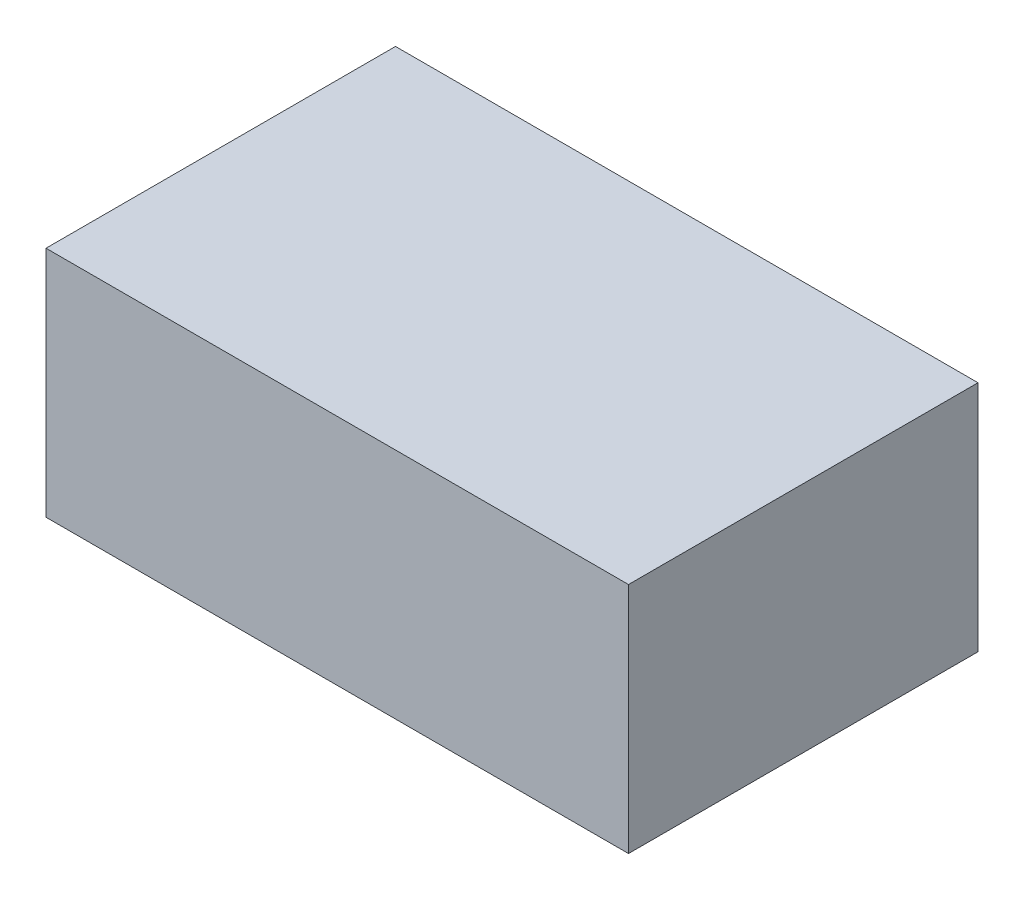
from build123d import *

# Parameters (mm, degrees)
SKETCH1_W           = 1
SKETCH1_H           = 0.6
BOSS_EXTRUDE1_DEPTH = 0.4
SKETCH2_W           = 0.25
SKETCH2_H           = 0.5
BOSS_EXTRUDE2_DEPTH = 0.05


with BuildPart() as part:
    # Sketch1 → Boss-Extrude1 (new body)
    with BuildSketch(Plane(origin=(0, 0, 0), x_dir=(1, 0, 0), z_dir=(0, 1, 0))):
        Rectangle(SKETCH1_W, SKETCH1_H)
    extrude(amount=BOSS_EXTRUDE1_DEPTH)

    # Sketch2 → Boss-Extrude2 (add)
    with BuildSketch(Plane.XZ):
        with Locations((-0.325, 0)):
            Rectangle(SKETCH2_W, SKETCH2_H)
        with Locations((0.325, 0)):
            Rectangle(SKETCH2_W, SKETCH2_H)
    extrude(amount=BOSS_EXTRUDE2_DEPTH)


solid = part.part
